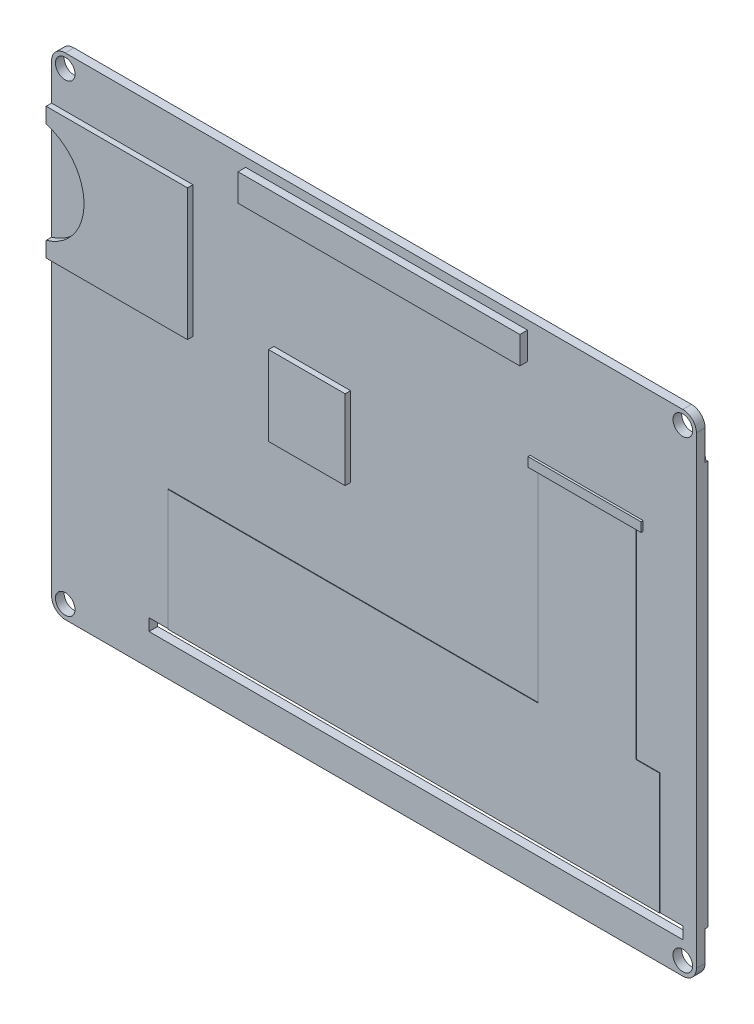
from build123d import *

# Parameters (mm, degrees)
SKETCH1_R           = 1.8
SKETCH1_W           = 98.1
SKETCH1_H           = 2.2
BOSS_EXTRUDE1_DEPTH = 1.6
BOSS_EXTRUDE2_DEPTH = 1
SKETCH4_W           = 14.077668093
SKETCH4_H           = 14.62437365
BOSS_EXTRUDE3_DEPTH = 1
SKETCH5_W           = 20.774811166
SKETCH5_H           = 1.698532112
BOSS_EXTRUDE4_DEPTH = 2
BOSS_EXTRUDE5_DEPTH = 0.1
SKETCH7_W           = 118.5
SKETCH7_H           = 74.2
BOSS_EXTRUDE6_DEPTH = 2.5
SKETCH9_W           = 118.5
SKETCH9_H           = 74.2
SKETCH9_W_2         = 113.57001823
SKETCH9_H_2         = 71.11304095
CUT_EXTRUDE1_DEPTH  = 2
SKETCH10_W          = 51.801411065
SKETCH10_H          = 5.00599424
BOSS_EXTRUDE7_DEPTH = 3


with BuildPart() as part:
    # Sketch1 → Boss-Extrude1 (new body)
    with BuildSketch(Plane.XY):
        with BuildLine():
            Line((-56.75, 45.1), (56.75, 45.1))
            ThreePointArc((56.75, 45.1), (58.517766953, 44.367766953), (59.25, 42.6))
            Line((59.25, 42.6), (59.25, -42.6))
            ThreePointArc((59.25, -42.6), (58.517766953, -44.367766953), (56.75, -45.1))
            Line((56.75, -45.1), (-56.75, -45.1))
            ThreePointArc((-56.75, -45.1), (-58.517766953, -44.367766953), (-59.25, -42.6))
            Line((-59.25, -42.6), (-59.25, 42.6))
            ThreePointArc((-59.25, 42.6), (-58.517766953, 44.367766953), (-56.75, 45.1))
        make_face()
        with Locations((-56.75, 42.6)):
            Circle(SKETCH1_R, mode=Mode.SUBTRACT)
        with Locations((-56.75, -42.6)):
            Circle(SKETCH1_R, mode=Mode.SUBTRACT)
        with Locations((56.75, -42.6)):
            Circle(SKETCH1_R, mode=Mode.SUBTRACT)
        with Locations((56.75, 42.6)):
            Circle(SKETCH1_R, mode=Mode.SUBTRACT)
        with Locations((7.7, -38.2)):
            Rectangle(SKETCH1_W, SKETCH1_H, mode=Mode.SUBTRACT)
    extrude(amount=BOSS_EXTRUDE1_DEPTH)

    # Sketch2 → Boss-Extrude2 (add)
    with BuildSketch(Plane.XY.offset(1.6)):
        with BuildLine():
            Line((-33.280179083, 35.852893933), (-59.25, 35.852893933))
            Line((-59.25, 35.852893933), (-59.25, 33.025293605))
            ThreePointArc((-59.25, 33.025293605), (-52.297040321, 23.771768976), (-59.25, 14.518244348))
            Line((-59.25, 14.518244348), (-59.25, 11.690644019))
            Line((-59.25, 11.690644019), (-33.280179083, 11.690644019))
            Line((-33.280179083, 11.690644019), (-33.280179083, 35.852893933))
        make_face()
    extrude(amount=BOSS_EXTRUDE2_DEPTH)

    # Sketch4 → Boss-Extrude3 (add)
    with BuildSketch(Plane.XY.offset(1.6)):
        with Locations((-11.344165308, 10.250729194)):
            Rectangle(SKETCH4_W, SKETCH4_H)
    extrude(amount=BOSS_EXTRUDE3_DEPTH)

    # Sketch5 → Boss-Extrude4 (add)
    with BuildSketch(Plane.XY):
        with Locations((39.089422326, 22.92250292)):
            Rectangle(SKETCH5_W, SKETCH5_H)
    extrude(amount=BOSS_EXTRUDE4_DEPTH)

    # Sketch6 → Boss-Extrude5 (add)
    with BuildSketch(Plane.XY.offset(1.6)):
        Polygon((30.227507475, 21.978150543), (48.227507475, 21.978150543), (48.227507475, -14.831552551), (52.545445223, -14.831552551), (52.545445223, -37.1), (-37.778090805, -37.1), (-37.778090805, -14.831552551), (30.227507475, -14.831552551), align=None)
    extrude(amount=BOSS_EXTRUDE5_DEPTH)

    # Sketch7 → Boss-Extrude6 (add)
    with BuildSketch(Plane.XY):
        Rectangle(SKETCH7_W, SKETCH7_H)
    extrude(amount=-BOSS_EXTRUDE6_DEPTH)

    # Sketch9 → Cut-Extrude1 (cut)
    with BuildSketch(Plane(origin=(0, 0, -2.5), x_dir=(-1, 0, 0), z_dir=(0, 0, -1))):
        Rectangle(SKETCH9_W, SKETCH9_H)
        Rectangle(SKETCH9_W_2, SKETCH9_H_2, mode=Mode.SUBTRACT)
    extrude(amount=-CUT_EXTRUDE1_DEPTH, mode=Mode.SUBTRACT)

    # Sketch10 → Boss-Extrude7 (add)
    with BuildSketch(Plane.XY):
        with Locations((2.305465736, 40.952943313)):
            Rectangle(SKETCH10_W, SKETCH10_H)
    extrude(amount=BOSS_EXTRUDE7_DEPTH)


solid = part.part
